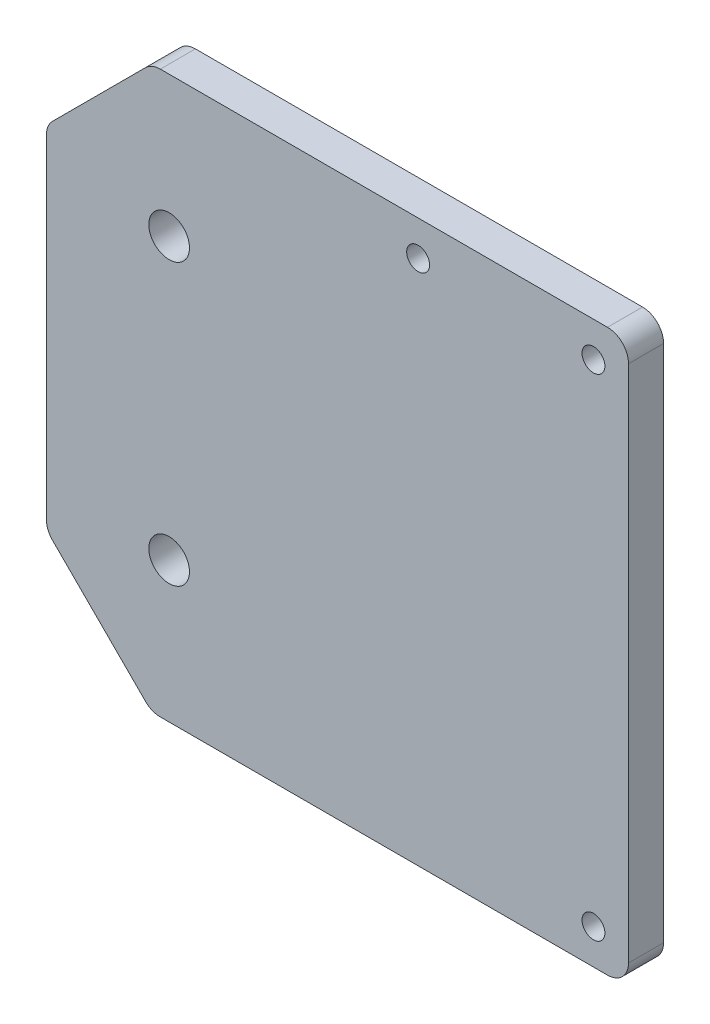
from build123d import *

# Parameters (mm, degrees)
BASE_W                = 83
BASE_H                = 80
MAIN_DEPTH            = 5
GEAR_AXIS_HOLES_D     = 5.8
CHAMFER1_SIZE         = 15
FILLET6_R             = 3
F_4_CLEARANCE_HOLE1_D = 3.2639


with BuildPart() as part:
    # Base → Main (new body)
    with BuildSketch(Plane.XY):
        with Locations((1.724154817, 0)):
            Rectangle(BASE_W, BASE_H)
    extrude(amount=MAIN_DEPTH)

    # Gear Axis Holes (through all)
    with Locations(Plane(origin=(0, 0, 5), x_dir=(-1, 0, 0), z_dir=(0, 0, 1))):
        with Locations((22.275845183, 20), (22.275845183, -20)):
            Hole(GEAR_AXIS_HOLES_D / 2)

    # Chamfer1
    chamfer1_edges = [part.edges().sort_by_distance(p)[0] for p in [
        (-39.775845183, -40, 2.5),
        (-39.775845183, 40, 2.5),
    ]]
    chamfer(chamfer1_edges, length=CHAMFER1_SIZE)

    # Fillet6
    fillet6_edges = [part.edges().sort_by_distance(p)[0] for p in [
        (-24.775845183, -40, 2.5),
        (-39.775845183, 25, 2.5),
        (-39.775845183, -25, 2.5),
        (-24.775845183, 40, 2.5),
        (43.224154817, 40, 2.5),
        (43.224154817, -40, 2.5),
    ]]
    fillet(fillet6_edges, radius=FILLET6_R)

    # #4 Clearance Hole1 (through all)
    with Locations(Plane.XY.offset(5)):
        with Locations((13.224154817, 35), (38.224154817, 35), (38.224154817, -35)):
            Hole(F_4_CLEARANCE_HOLE1_D / 2)


solid = part.part
